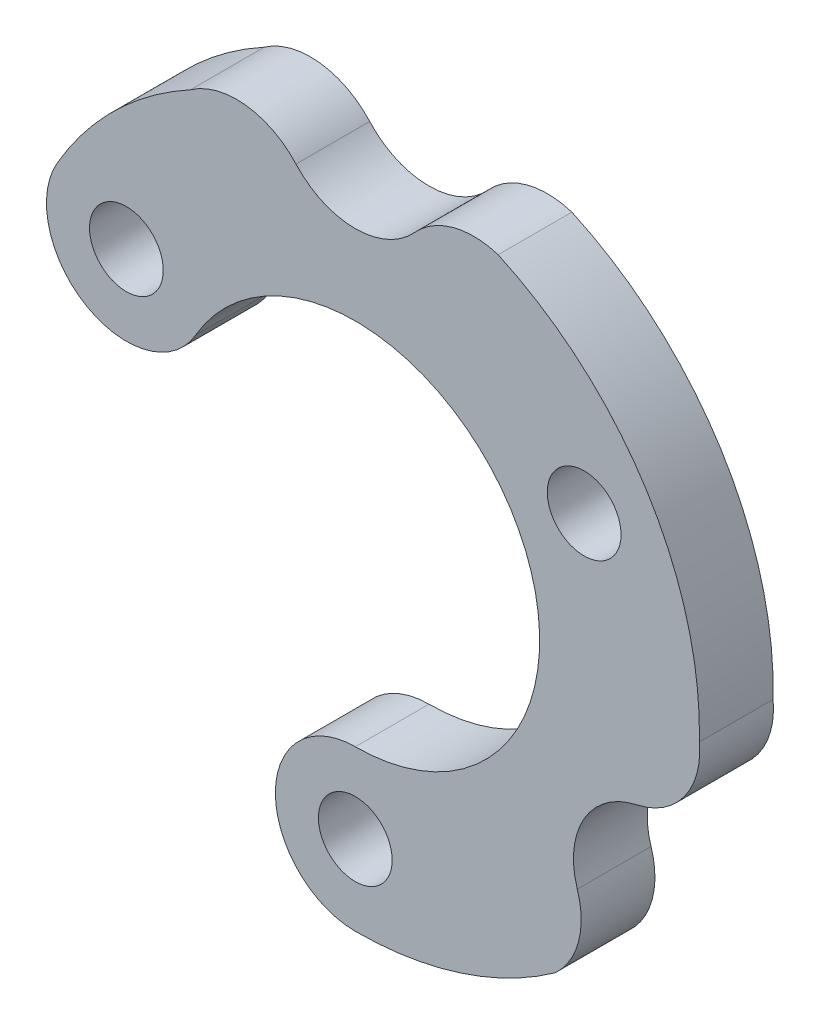
from build123d import *

# Parameters (mm, degrees)
ESQUISSE1_R        = 1.5
BOSS_EXTRU_2_DEPTH = 3


with BuildPart() as part:
    # Esquisse1 → Boss.-Extru.2 (new body)
    with BuildSketch(Plane.XY):
        with BuildLine():
            ThreePointArc((-2.411034891, 11.820685714), (0, 10.75), (2.411034891, 11.820685714))
            ThreePointArc((2.411034891, 11.820685714), (3.975330286, 12.779130538), (5.80943088, 12.737759334))
            ThreePointArc((5.80943088, 12.737759334), (11.865562564, 7.430237213), (13.995977593, -0.335575935))
            ThreePointArc((13.995977593, -0.335575935), (13.382779595, -2.564868949), (11.442531564, -3.822325392))
            ThreePointArc((11.442531564, -3.822325392), (9.309773091, -5.375), (9.031496673, -7.998360322))
            ThreePointArc((9.031496673, -7.998360322), (9.079386541, -9.832302285), (8.126507731, -11.399994391))
            ThreePointArc((8.126507731, -11.399994391), (4.266150404, -13.334165168), (0, -14))
            ThreePointArc((0, -14), (-3.25, -10.75), (0, -7.5))
            ThreePointArc((0, -7.5), (6.495190528, 3.75), (-6.495190528, 3.75))
            ThreePointArc((-6.495190528, 3.75), (-10.934773091, 2.560417438), (-12.124355653, 7))
            ThreePointArc((-12.124355653, 7), (-9.780131311, 10.017436376), (-6.707371512, 12.288660114))
            ThreePointArc((-6.707371512, 12.288660114), (-4.47014813, 12.872261577), (-2.411034891, 11.820685714))
        make_face()
        with Locations((9.309773091, 5.375)):
            Circle(ESQUISSE1_R, mode=Mode.SUBTRACT)
        with Locations((0, -10.75)):
            Circle(ESQUISSE1_R, mode=Mode.SUBTRACT)
        with Locations((-9.309773091, 5.375)):
            Circle(ESQUISSE1_R, mode=Mode.SUBTRACT)
    extrude(amount=BOSS_EXTRU_2_DEPTH)


solid = part.part
